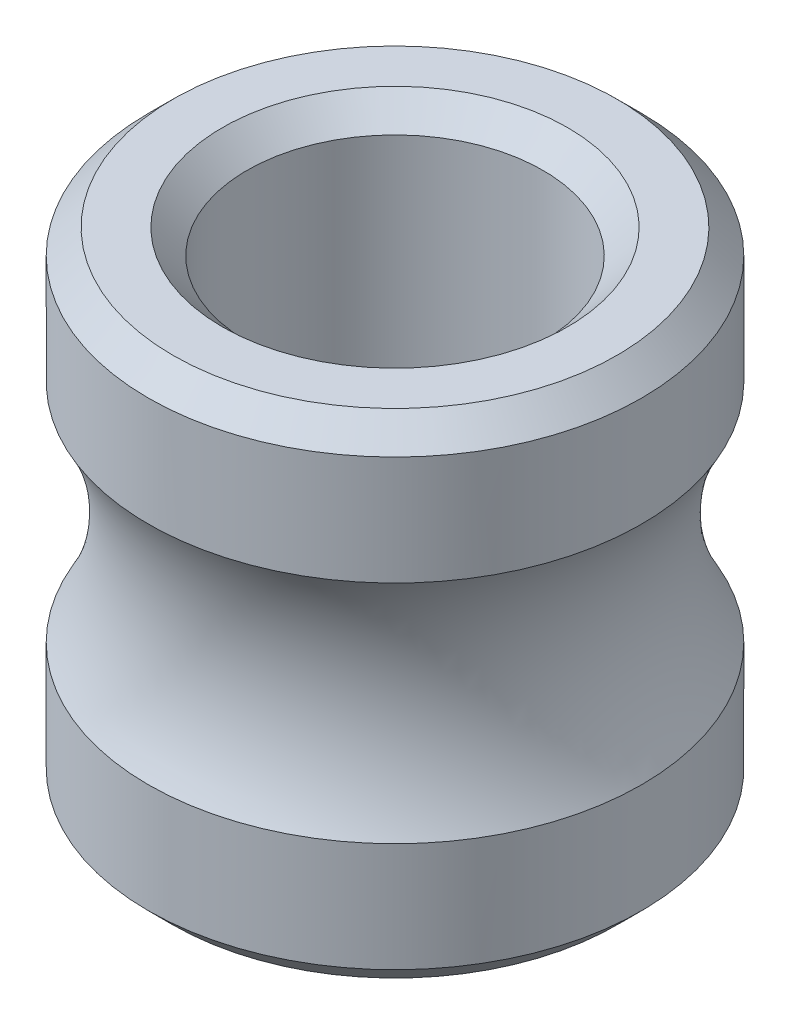
from build123d import *

# Parameters (mm, degrees)
SKETCH1_R           = 2
SKETCH1_R_2         = 1.2
BOSS_EXTRUDE1_DEPTH = 2
CHAMFER1_SIZE       = 0.2
SKETCH2_R           = 1.8


with BuildPart() as part:
    # Sketch1 → Boss-Extrude1 (new body, symmetric)
    with BuildSketch(Plane(origin=(0, 0, 0), x_dir=(1, 0, 0), z_dir=(0, 1, 0))):
        Circle(SKETCH1_R)
        Circle(SKETCH1_R_2, mode=Mode.SUBTRACT)
    extrude(amount=BOSS_EXTRUDE1_DEPTH, both=True)

    # Chamfer1
    chamfer1_edges = [part.edges().sort_by_distance(p)[0] for p in [
        (-2, -2, 0),
        (-2, 2, 0),
        (-1.2, -2, 0),
        (-1.2, 2, 0),
    ]]
    chamfer(chamfer1_edges, length=CHAMFER1_SIZE)

    # Cut-Sweep1: sweep along a path in Sketch3
    with BuildLine(Plane(origin=(0, 0, 0), x_dir=(1, 0, 0), z_dir=(0, 1, 0))) as cut_sweep1_path:
        CenterArc((0, 0), 3.553150672, 0, 360)
    # Sketch2 → Cut-Sweep1 (sweep, cut)
    with BuildSketch(Plane(origin=(0, 0, 0), x_dir=(0, 0, -1), z_dir=(1, 0, 0))):
        with Locations((3.55, 0)):
            Circle(SKETCH2_R)
    sweep(path=cut_sweep1_path.line, mode=Mode.SUBTRACT)


solid = part.part
